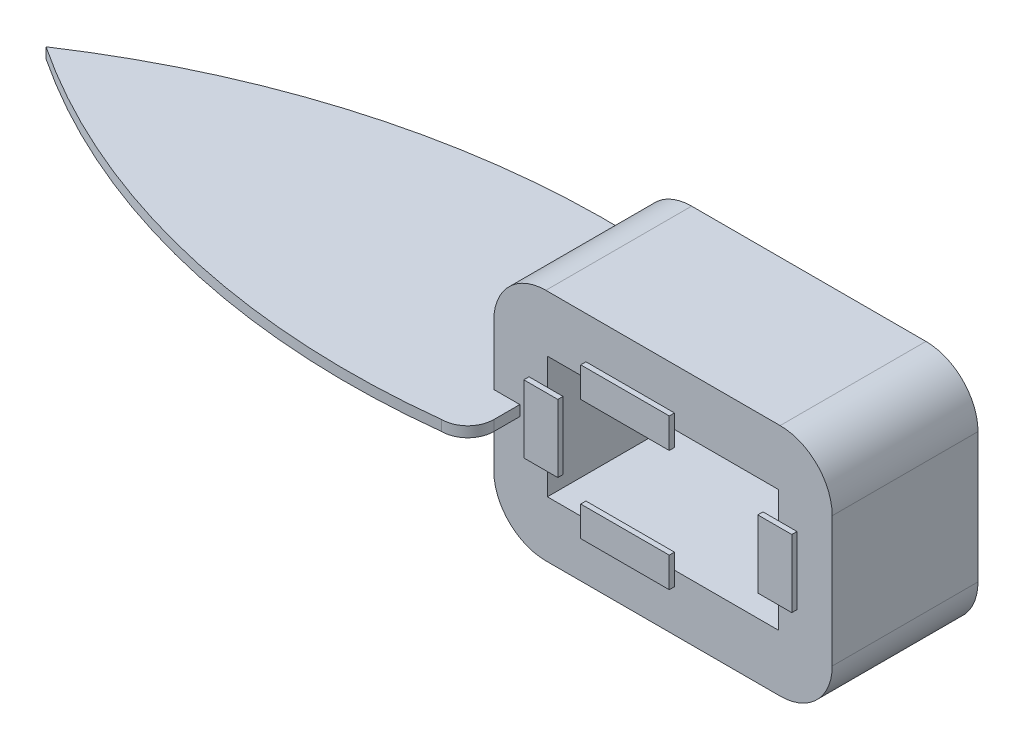
from build123d import *

# Parameters (mm, degrees)
SKETCH_1_W           = 65
SKETCH_1_H           = 45
EXTRUDE_1_DEPTH      = 28
SKETCH_2_W           = 44.4
SKETCH_2_H           = 23.4
CUT_EXTRUDE_1_DEPTH  = 39
FILLET_1_R           = 10
FILLET_2_R           = 10
FILLET_3_R           = 10
FILLET_4_R           = 10
EXTRUDE_6_DEPTH      = 1
EXTRUDE_6_2_DEPTH    = 1
EXTRUDE_6_3_DEPTH    = 1
SKETCH_10_W          = 17
SKETCH_10_H          = 5.754584259
EXTRUDE_6_4_DEPTH    = 1
SKETCH_20_W          = 5.002637397
SKETCH_20_H          = 2
EXTRUDE_7_DEPTH      = 10
SKETCH_21_W          = 5.00232547
SKETCH_21_H          = 2
EXTRUDE_8_DEPTH      = 10
EXTRUDE_9_DEPTH      = 1
EXTRUDE_9_DEPTH_BACK = 1
FILLET_5_R           = 5
FILLET_6_R           = 5


with BuildPart() as part:
    # 草圖1 → 填料-伸長1 (new body)
    with BuildSketch(Plane.XY):
        with Locations((-27.434655272, 0)):
            Rectangle(SKETCH_1_W, SKETCH_1_H)
    extrude(amount=EXTRUDE_1_DEPTH)

    # 草圖2 → 除料-伸長1 (cut)
    with BuildSketch(Plane.XY):
        with Locations((-27.434655272, 0)):
            Rectangle(SKETCH_2_W, SKETCH_2_H)
    extrude(amount=CUT_EXTRUDE_1_DEPTH, mode=Mode.SUBTRACT)

    # 圓角1
    fillet_1_edges = [part.edges().sort_by_distance(p)[0] for p in [
        (-59.934655272, -22.5, 14),
    ]]
    fillet(fillet_1_edges, radius=FILLET_1_R)

    # 圓角2
    fillet_2_edges = [part.edges().sort_by_distance(p)[0] for p in [
        (-59.934655272, 22.5, 14),
    ]]
    fillet(fillet_2_edges, radius=FILLET_2_R)

    # 圓角3
    fillet_3_edges = [part.edges().sort_by_distance(p)[0] for p in [
        (5.065344728, 22.5, 14),
    ]]
    fillet(fillet_3_edges, radius=FILLET_3_R)

    # 圓角4
    fillet_4_edges = [part.edges().sort_by_distance(p)[0] for p in [
        (5.065344728, -22.5, 14),
    ]]
    fillet(fillet_4_edges, radius=FILLET_4_R)

    # 草圖20 → 填料-伸長7 (add)
    with BuildSketch(Plane.XY.offset(28)):
        with Locations((-57.433336574, 0)):
            Rectangle(SKETCH_20_W, SKETCH_20_H)
    extrude(amount=EXTRUDE_7_DEPTH)

    # 草圖21 → 填料-伸長8 (add)
    with BuildSketch(Plane(origin=(0, 0, 0), x_dir=(-1, 0, 0), z_dir=(0, 0, -1))):
        with Locations((57.433492537, 0)):
            Rectangle(SKETCH_21_W, SKETCH_21_H)
    extrude(amount=EXTRUDE_8_DEPTH)

    # 草圖22 → 填料-伸長9 (add, two sides)
    with BuildSketch(Plane(origin=(0, 0, 0), x_dir=(1, 0, 0), z_dir=(0, 1, 0))) as extrude_9_sk:
        with BuildLine():
            Line((-59.934655272, 10), (-59.934655272, -38))
            ThreePointArc((-59.934655272, -38), (-112.055707444, -34.837717383), (-159.934655272, -14))
            ThreePointArc((-159.934655272, -14), (-112.055707444, 6.837717383), (-59.934655272, 10))
        make_face()
    extrude(amount=EXTRUDE_9_DEPTH)
    extrude(extrude_9_sk.sketch, amount=-EXTRUDE_9_DEPTH_BACK)

    # 圓角5
    fillet_5_edges = [part.edges().sort_by_distance(p)[0] for p in [
        (-54.932329802, 0, -10),
    ]]
    fillet(fillet_5_edges, radius=FILLET_5_R)

    # 圓角6
    fillet_6_edges = [part.edges().sort_by_distance(p)[0] for p in [
        (-54.932017875, 0, 38),
    ]]
    fillet(fillet_6_edges, radius=FILLET_6_R)


with BuildPart() as body_2:
    # 草圖10 → 填料-伸長6 (new body)
    with BuildSketch(Plane.XY.offset(29)):
        Polygon((-49.634655272, 6.5), (-53.165057103, 6.5), (-53.165057103, -6.5), (-46.634655272, -6.5), (-46.634655272, 6.5), align=None)
    extrude(amount=-EXTRUDE_6_DEPTH)


with BuildPart() as body_3:
    # 草圖10 → Extrude 6 2 (new body)
    with BuildSketch(Plane.XY.offset(29)):
        Polygon((-42.234655272, -11.7), (-42.234655272, -8.7), (-25.234655272, -8.7), (-25.234655272, -14.454584259), (-42.234655272, -14.454584259), align=None)
    extrude(amount=-EXTRUDE_6_2_DEPTH)


with BuildPart() as body_4:
    # 草圖10 → Extrude 6 3 (new body)
    with BuildSketch(Plane.XY.offset(29)):
        Polygon((-8.234655272, 6.5), (-8.234655272, -6.5), (-5.234655272, -6.5), (-1.70425344, -6.5), (-1.70425344, 6.5), align=None)
    extrude(amount=-EXTRUDE_6_3_DEPTH)


with BuildPart() as body_5:
    # 草圖10 → Extrude 6 4 (new body)
    with BuildSketch(Plane.XY.offset(29)):
        with Locations((-33.734655272, 11.57729213)):
            Rectangle(SKETCH_10_W, SKETCH_10_H)
    extrude(amount=-EXTRUDE_6_4_DEPTH)


solid = Compound([part.part, body_2.part, body_3.part, body_4.part, body_5.part])
